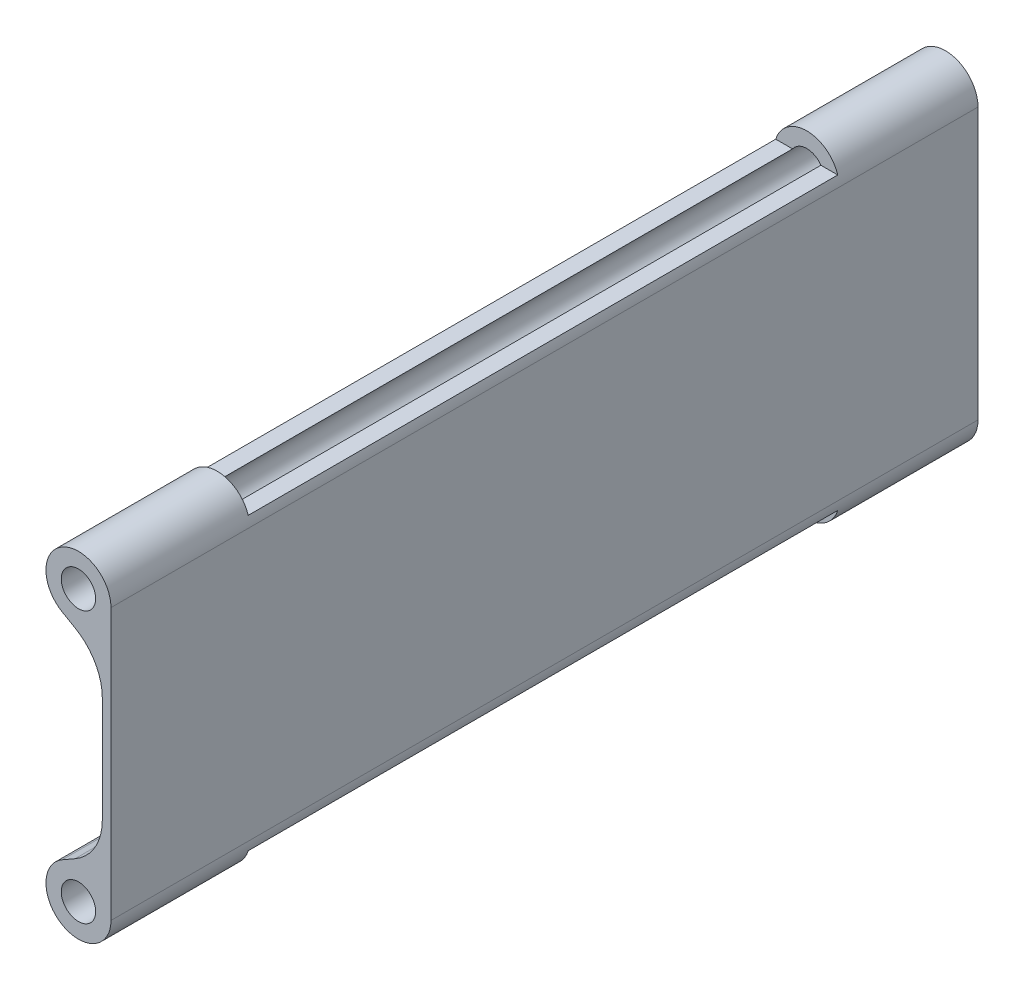
from build123d import *

# Parameters (mm, degrees)
CROQUIS1_R              = 3.175
SALIENTE_EXTRUIR1_DEPTH = 160
REDONDEO1_R             = 10
CROQUIS3_W              = 108.791812306
CROQUIS3_H              = 18.145434914
CORTAR_EXTRUIR2_DEPTH   = 13


with BuildPart() as part:
    # Croquis1 → Saliente-Extruir1 (new body)
    with BuildSketch(Plane.XY):
        with BuildLine():
            Line((-1.6, 15.556228096), (-8.98691391, 19.796314259))
            ThreePointArc((-8.98691391, 19.796314259), (-9.006535925, 30.19237342), (0, 25))
            Line((0, 25), (0, -25))
            ThreePointArc((0, -25), (-9.006535925, -30.19237342), (-8.98691391, -19.796314259))
            Line((-8.98691391, -19.796314259), (-1.6, -15.556228096))
            Line((-1.6, -15.556228096), (-1.6, 15.556228096))
        make_face()
        with Locations((-6, 25)):
            Circle(CROQUIS1_R, mode=Mode.SUBTRACT)
        with Locations((-6, -25)):
            Circle(CROQUIS1_R, mode=Mode.SUBTRACT)
    extrude(amount=-SALIENTE_EXTRUIR1_DEPTH)

    # Redondeo1
    redondeo1_edges = [part.edges().sort_by_distance(p)[0] for p in [
        (-1.6, -15.556228096, -80),
        (-1.6, 15.556228096, -80),
    ]]
    fillet(redondeo1_edges, radius=REDONDEO1_R)

    # Croquis3 → Cortar-Extruir2 (cut, through all)
    with BuildSketch(Plane(origin=(0, 0, 0), x_dir=(0, 0, -1), z_dir=(1, 0, 0))):
        with Locations((80, 35.875128035)):
            Rectangle(CROQUIS3_W, CROQUIS3_H)
        with Locations((80, -35.875128035)):
            Rectangle(CROQUIS3_W, CROQUIS3_H)
    extrude(amount=-CORTAR_EXTRUIR2_DEPTH, mode=Mode.SUBTRACT)


solid = part.part
